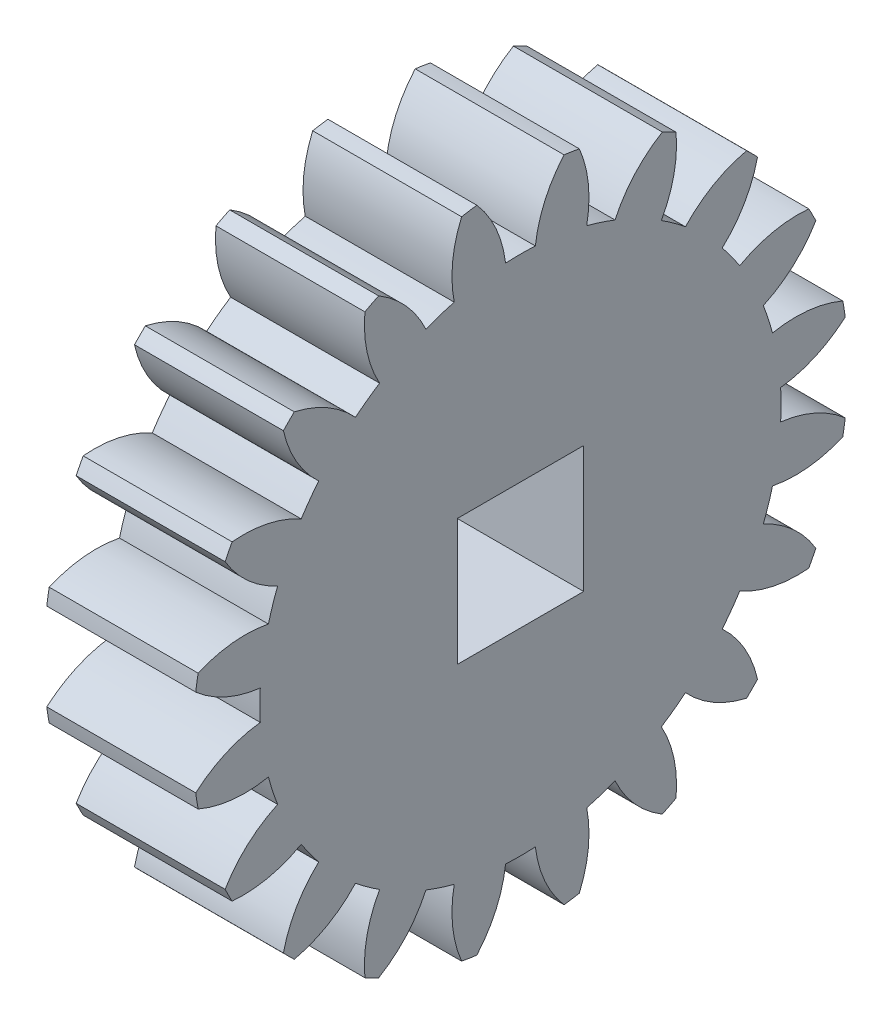
from build123d import *

# Parameters (mm, degrees)
BASPROSKE_W        = 5
BASPROSKE_H        = 11
TOOTHCUT_DEPTH     = 17.340134638
TEETHCUTS_COUNT    = 20
TEETHCUTS_ANGLE    = 342
BORSKE_R           = 0.4
BORE_DEPTH         = 50.0000508
SKETCH1_W          = 4.242640688
SKETCH1_H          = 4.242640688
CUT_EXTRUDE1_DEPTH = 17.208263488


with BuildPart() as part:
    # BasProSke → Base-Revolve (revolve)
    with BuildSketch(Plane(origin=(0, 0, 0), x_dir=(1, 0, 0), z_dir=(0, 1, 0)), mode=Mode.PRIVATE) as base_revolve_sk:
        with Locations((2.5, 5.5)):
            Rectangle(BASPROSKE_W, BASPROSKE_H)
    revolve(base_revolve_sk.sketch.rotate(Axis((-10, 0, 0), (1, 0, 0)), 180), axis=Axis((-10, 0, 0), (1, 0, 0)))

    # TooCutSke → ToothCut (cut, through all)
    with BuildSketch(Plane(origin=(0, 0, 0), x_dir=(0, 0, -1), z_dir=(1, 0, 0))):
        with BuildLine():
            ThreePointArc((0.499924007, 8.734705318), (0, 8.749), (-0.499924007, 8.734705318))
            ThreePointArc((-0.499924007, 8.734705318), (-0.824302243, 9.905497836), (-1.485192705, 10.924909509))
            ThreePointArc((-1.485192705, 10.924909509), (0, 11.0254), (1.485192705, 10.924909509))
            ThreePointArc((1.485192705, 10.924909509), (0.824302243, 9.905497836), (0.499924007, 8.734705318))
        make_face()
    toothcut = extrude(amount=TOOTHCUT_DEPTH, mode=Mode.SUBTRACT)

    # TeethCuts: ToothCut ×20 about axis
    teethcuts_axis = Axis((-10, 0, 0), (1, 0, 0))
    for i in range(1, TEETHCUTS_COUNT):
        add(toothcut.rotate(teethcuts_axis, i * TEETHCUTS_ANGLE / (TEETHCUTS_COUNT - 1)), mode=Mode.SUBTRACT)

    # BorSke → Bore (cut, symmetric)
    with BuildSketch(Plane(origin=(0, 0, 0), x_dir=(0, 0, -1), z_dir=(1, 0, 0))):
        with Locations(Location((0, 0, 0), (0, 0, 180))):
            Circle(BORSKE_R)
    extrude(amount=BORE_DEPTH, both=True, mode=Mode.SUBTRACT)

    # Sketch1 → Cut-Extrude1 (cut, through all)
    with BuildSketch(Plane(origin=(5, 0, 0), x_dir=(0, 0, -1), z_dir=(1, 0, 0))):
        Rectangle(SKETCH1_W, SKETCH1_H)
    extrude(amount=-CUT_EXTRUDE1_DEPTH, mode=Mode.SUBTRACT)


solid = part.part
